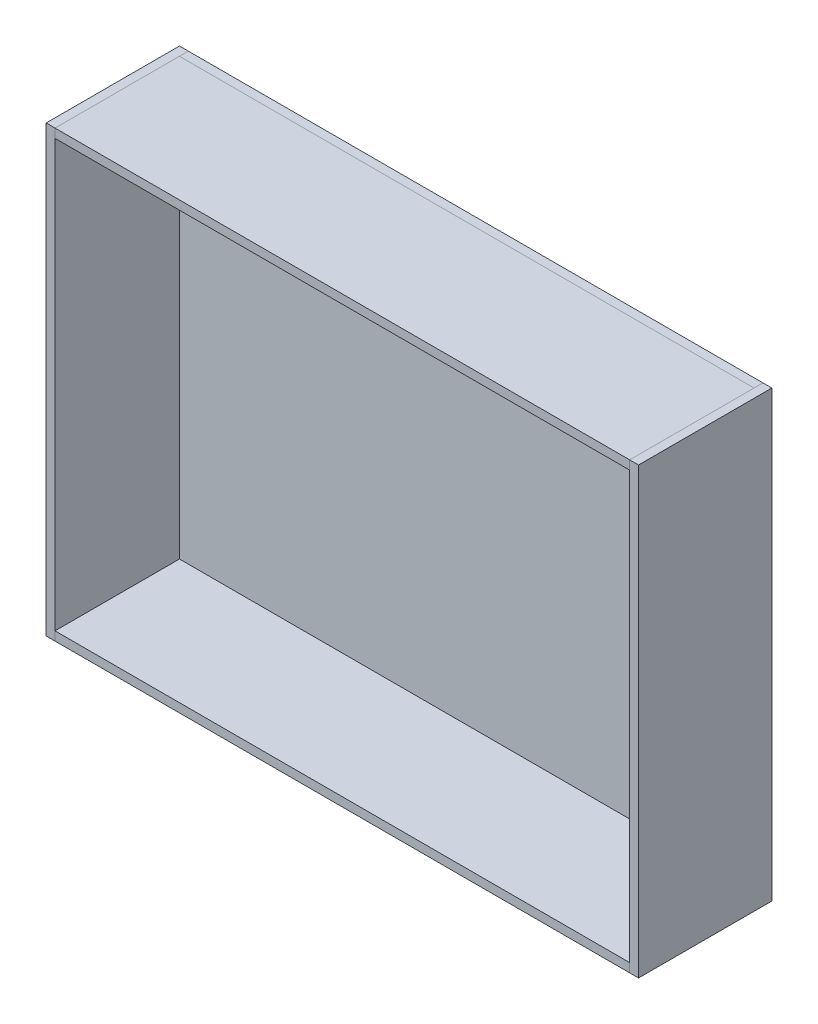
from build123d import *

# Parameters (mm, degrees)
ESQUISSE1_W          = 194
ESQUISSE1_H          = 150
BOSS_EXTRU_1_DEPTH   = 3
ESQUISSE3_W          = 3
ESQUISSE3_H          = 45
BOSS_EXTRU_3_DEPTH   = 150
BOSS_EXTRU_3_2_DEPTH = 150
ESQUISSE4_W          = 194
ESQUISSE4_H          = 3
BOSS_EXTRU_4_DEPTH   = 42
BOSS_EXTRU_4_2_DEPTH = 42


with BuildPart() as part:
    # Esquisse1 → Boss.-Extru.1 (new body)
    with BuildSketch(Plane.XY):
        Rectangle(ESQUISSE1_W, ESQUISSE1_H)
    extrude(amount=BOSS_EXTRU_1_DEPTH)


with BuildPart() as body_2:
    # Esquisse3 → Boss.-Extru.3 (new body)
    with BuildSketch(Plane(origin=(0, 75, 0), x_dir=(1, 0, 0), z_dir=(0, 1, 0))):
        with Locations((-98.5, -22.5)):
            Rectangle(ESQUISSE3_W, ESQUISSE3_H)
    extrude(amount=-BOSS_EXTRU_3_DEPTH)


with BuildPart() as body_3:
    # Esquisse3 → Boss.-Extru.3 2 (new body)
    with BuildSketch(Plane(origin=(0, 75, 0), x_dir=(1, 0, 0), z_dir=(0, 1, 0))):
        with Locations((98.5, -22.5)):
            Rectangle(ESQUISSE3_W, ESQUISSE3_H)
    extrude(amount=-BOSS_EXTRU_3_2_DEPTH)


with BuildPart() as body_4:
    # Esquisse4 → Boss.-Extru.4 (new body)
    with BuildSketch(Plane.XY.offset(3)):
        with Locations((0, 73.5)):
            Rectangle(ESQUISSE4_W, ESQUISSE4_H)
    extrude(amount=BOSS_EXTRU_4_DEPTH)


with BuildPart() as body_5:
    # Esquisse4 → Boss.-Extru.4 2 (new body)
    with BuildSketch(Plane.XY.offset(3)):
        with Locations((0, -73.5)):
            Rectangle(ESQUISSE4_W, ESQUISSE4_H)
    extrude(amount=BOSS_EXTRU_4_2_DEPTH)


solid = Compound([part.part, body_2.part, body_3.part, body_4.part, body_5.part])
